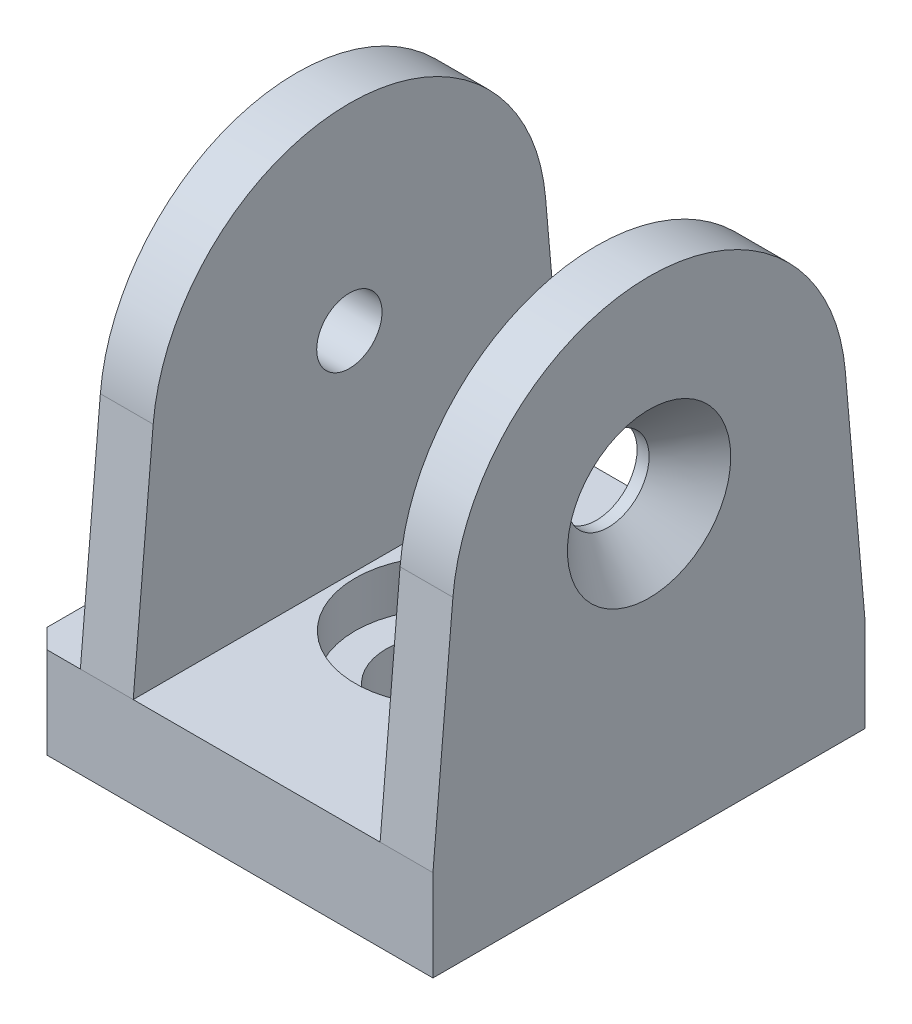
from build123d import *

# Parameters (mm, degrees)
SKETCH_1_W               = 42.2
SKETCH_1_H               = 45
EXTRUDE_1_DEPTH          = 9.5
EXTRUDE_2_DEPTH          = 36.7
SKETCH_4_W               = 25.7
SKETCH_4_H               = 42.5
CUT_EXTRUDE_1_DEPTH      = 23.5
CUT_EXTRUDE_1_DEPTH_BACK = 23.5
CHAMFER_1_SIZE           = 2
HOLE_WIZARD_M81_D        = 6.8
HOLE_WIZARD_M81_DEPTH    = 5.5


with BuildPart() as part:
    # Эскиз1 → Бобышка-Вытянуть1 (new body)
    with BuildSketch(Plane(origin=(0, 0, 0), x_dir=(1, 0, 0), z_dir=(0, 1, 0))):
        Rectangle(SKETCH_1_W, SKETCH_1_H)
    extrude(amount=EXTRUDE_1_DEPTH)

    # Эскиз2 → Вырез-Повернуть1 (revolve, cut)
    with BuildSketch(Plane.XY):
        Polygon((-6.25, 0), (-6.25, 4.75), (-9.5, 4.75), (-9.5, 9.5), (0, 9.5), (0, 0), align=None)
    revolve(axis=Axis((0, 9.5, 0), (0, -1, 0)), mode=Mode.SUBTRACT)

    # Эскиз3 → Бобышка-Вытянуть2 (add)
    with BuildSketch(Plane(origin=(21.1, 0, 0), x_dir=(0, 0, -1), z_dir=(1, 0, 0))):
        with BuildLine():
            Line((-22.5, 9.5), (-20.422219056, 33.284087671))
            ThreePointArc((-20.422219056, 33.284087671), (0, 52), (20.422219056, 33.284087671))
            Line((20.422219056, 33.284087671), (22.5, 9.5))
            Line((22.5, 9.5), (-22.5, 9.5))
        make_face()
    extrude(amount=-EXTRUDE_2_DEPTH)

    # Эскиз4 → Вырез-Вытянуть1 (cut, two sides)
    with BuildSketch(Plane.XY) as cut_extrude_1_sk:
        with Locations((2.75, 30.75)):
            Rectangle(SKETCH_4_W, SKETCH_4_H)
    extrude(amount=CUT_EXTRUDE_1_DEPTH, mode=Mode.SUBTRACT)
    extrude(cut_extrude_1_sk.sketch, amount=-CUT_EXTRUDE_1_DEPTH_BACK, mode=Mode.SUBTRACT)

    # Фаска1
    chamfer_1_edges = [part.edges().sort_by_distance(p)[0] for p in [
        (-21.1, 4.75, -22.5),
        (-21.1, 4.75, 22.5),
    ]]
    chamfer(chamfer_1_edges, length=CHAMFER_1_SIZE)

    # Эскиз10 → Зенковка для винта с полупотайной головкой 1 (revolve, cut)
    with BuildSketch(Plane(origin=(21.1, 31.5, 0), x_dir=(0, 0, -1), z_dir=(0, 1, 0))):
        Polygon((0, 0), (0, 5.5), (4.25, 5.5), (4.25, 4.25), (8.5, 0), align=None)
    revolve(axis=Axis((27.45, 31.5, 0), (-1, 0, 0)), mode=Mode.SUBTRACT)

    # Отверстие обработанное метчиком M81
    with Locations(Plane.ZY.offset(15.6)):
        with Locations((0, 31.5)):
            Hole(HOLE_WIZARD_M81_D / 2, depth=HOLE_WIZARD_M81_DEPTH)


solid = part.part
